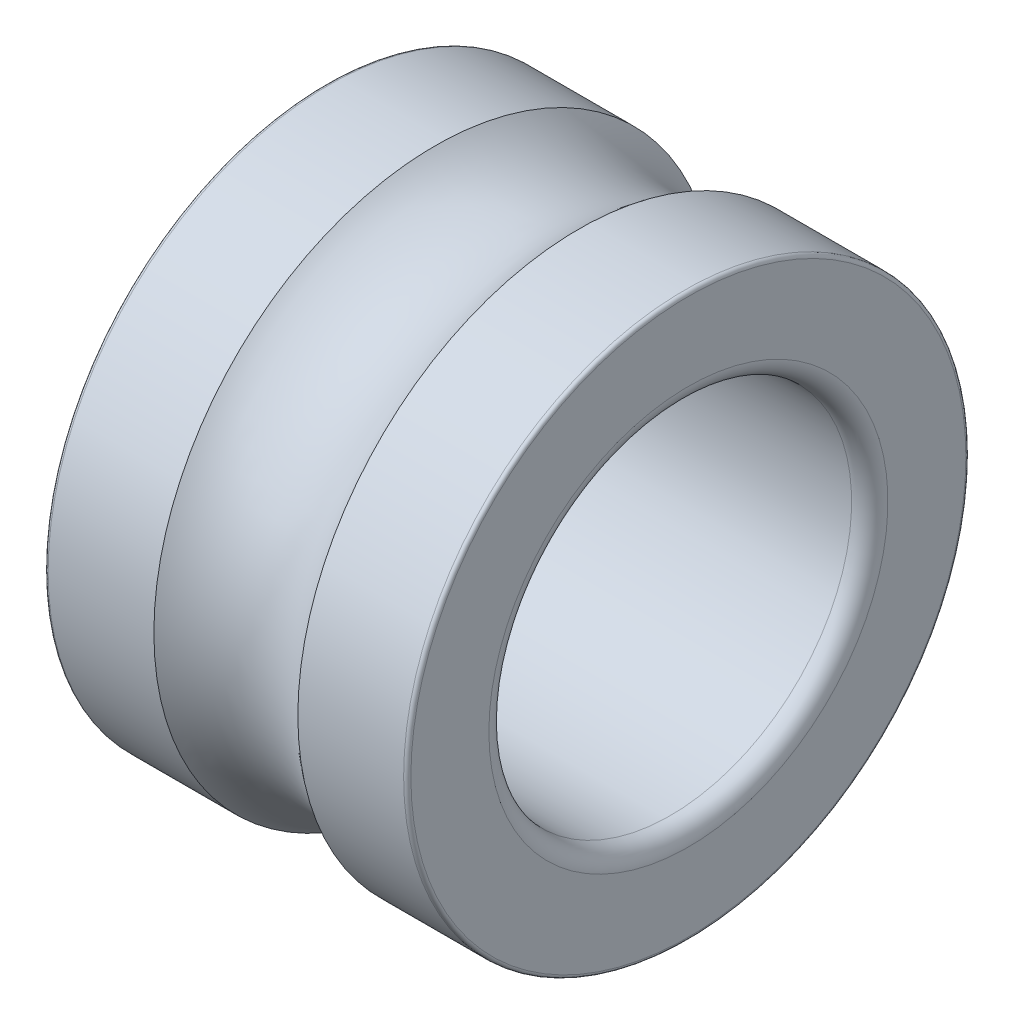
from build123d import *


with BuildPart() as part:
    # Sketch1 → Revolve1 (revolve)
    with BuildSketch(Plane.XY):
        with BuildLine():
            Line((0, 0.765), (0, 0.55))
            ThreePointArc((0, 0.55), (0.014644661, 0.514644661), (0.05, 0.5))
            Line((0.05, 0.5), (0.95, 0.5))
            ThreePointArc((0.95, 0.5), (0.985355339, 0.514644661), (1, 0.55))
            Line((1, 0.55), (1, 0.765))
            ThreePointArc((1, 0.765), (0.997071068, 0.772071068), (0.99, 0.775))
            Line((0.99, 0.775), (0.698431348, 0.775))
            ThreePointArc((0.698431348, 0.775), (0.5, 0.7), (0.301568652, 0.775))
            Line((0.301568652, 0.775), (0.01, 0.775))
            ThreePointArc((0.01, 0.775), (0.002928932, 0.772071068), (0, 0.765))
        make_face()
    revolve(axis=Axis((50, 0, 0), (-1, 0, 0)))


solid = part.part
